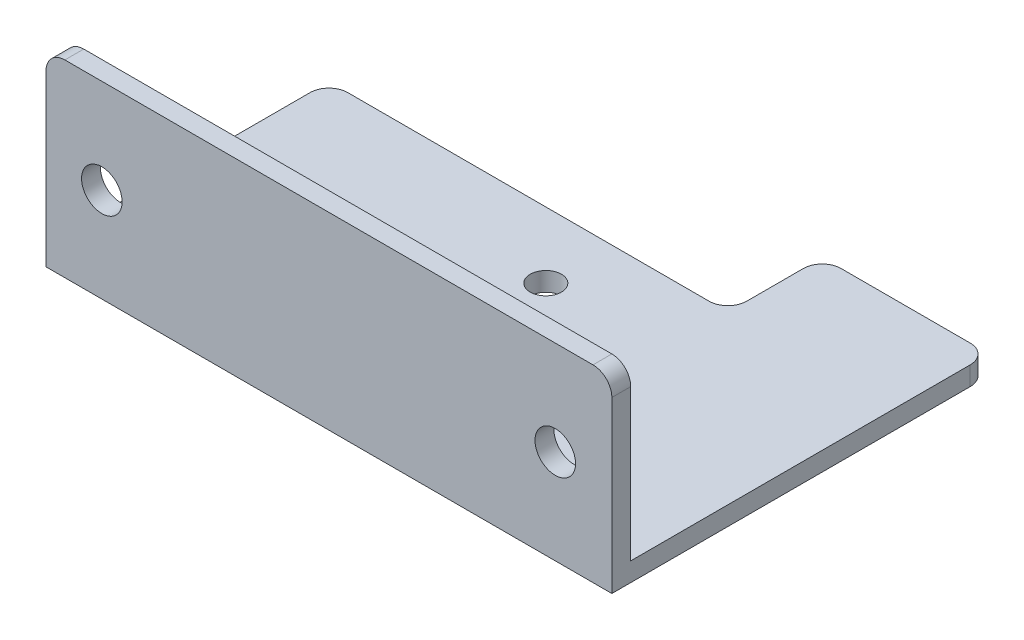
from build123d import *

# Parameters (mm, degrees)
SKETCH_1_W      = 60
SKETCH_1_H      = 30
SKETCH_1_R      = 1.65
EXTRUDE_3_DEPTH = 2
SKETCH_3_W      = 60
SKETCH_3_H      = 20
SKETCH_3_R      = 2.15
EXTRUDE_4_DEPTH = 2
SKETCH_4_W      = 17.695256038
SKETCH_4_H      = 10
EXTRUDE_5_DEPTH = 2
FILLET_1_R      = 2
FILLET_2_R      = 2
FILLET_3_R      = 2
FILLET_4_R      = 2
FILLET_5_R      = 2
FILLET_6_R      = 2


with BuildPart() as part:
    # 草图1 → 凸台-拉伸3 (new body)
    with BuildSketch(Plane(origin=(0, 0, 0), x_dir=(1, 0, 0), z_dir=(0, 1, 0))):
        Rectangle(SKETCH_1_W, SKETCH_1_H)
        with Locations((0, 8)):
            Circle(SKETCH_1_R, mode=Mode.SUBTRACT)
        with Locations((0, -8)):
            Circle(SKETCH_1_R, mode=Mode.SUBTRACT)
        with Locations((8, 0)):
            Circle(SKETCH_1_R, mode=Mode.SUBTRACT)
        with Locations((-8, 0)):
            Circle(SKETCH_1_R, mode=Mode.SUBTRACT)
    extrude(amount=EXTRUDE_3_DEPTH)

    # 草图3 → 凸台-拉伸4 (add)
    with BuildSketch(Plane.XY.offset(15)):
        with Locations((0, 10)):
            Rectangle(SKETCH_3_W, SKETCH_3_H)
        with Locations((24, 10)):
            Circle(SKETCH_3_R, mode=Mode.SUBTRACT)
        with Locations((-24.08, 10)):
            Circle(SKETCH_3_R, mode=Mode.SUBTRACT)
    extrude(amount=-EXTRUDE_4_DEPTH)

    # 草图4 → 凸台-拉伸5 (add)
    with BuildSketch(Plane(origin=(0, 2, 0), x_dir=(1, 0, 0), z_dir=(0, 1, 0))):
        with Locations((21.152371981, 20)):
            Rectangle(SKETCH_4_W, SKETCH_4_H)
    extrude(amount=-EXTRUDE_5_DEPTH)

    # 圆角1
    fillet_1_edges = [part.edges().sort_by_distance(p)[0] for p in [
        (30, 1, -25),
    ]]
    fillet(fillet_1_edges, radius=FILLET_1_R)

    # 圆角2
    fillet_2_edges = [part.edges().sort_by_distance(p)[0] for p in [
        (12.304743962, 1, -25),
    ]]
    fillet(fillet_2_edges, radius=FILLET_2_R)

    # 圆角3
    fillet_3_edges = [part.edges().sort_by_distance(p)[0] for p in [
        (12.304743962, 1, -15),
    ]]
    fillet(fillet_3_edges, radius=FILLET_3_R)

    # 圆角4
    fillet_4_edges = [part.edges().sort_by_distance(p)[0] for p in [
        (-30, 1, -15),
    ]]
    fillet(fillet_4_edges, radius=FILLET_4_R)

    # 圆角5
    fillet_5_edges = [part.edges().sort_by_distance(p)[0] for p in [
        (-30, 20, 14),
    ]]
    fillet(fillet_5_edges, radius=FILLET_5_R)

    # 圆角6
    fillet_6_edges = [part.edges().sort_by_distance(p)[0] for p in [
        (30, 20, 14),
    ]]
    fillet(fillet_6_edges, radius=FILLET_6_R)


solid = part.part
